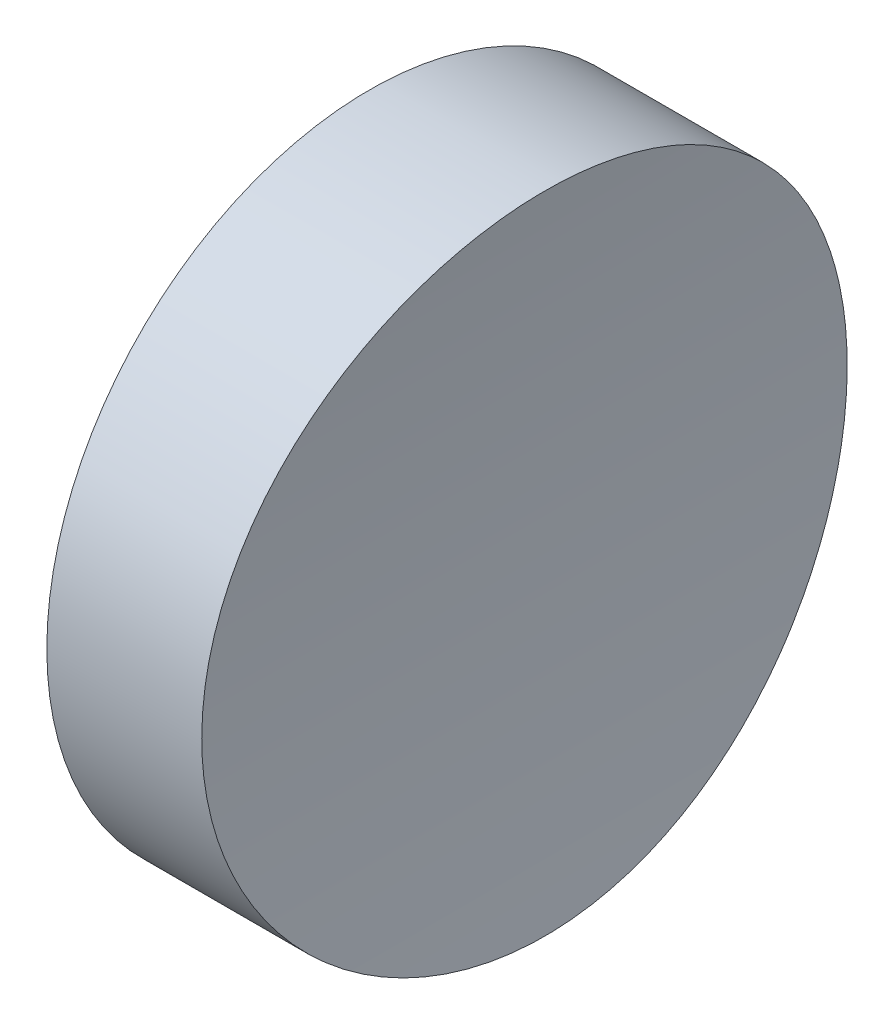
from build123d import *

# Parameters (mm, degrees)
SKETCH_1_R               = 6.25
EXTRUDE_1_DEPTH          = 10
SKETCH_2_R               = 50
CUT_EXTRUDE_1_DEPTH      = 7.25
CUT_EXTRUDE_1_DEPTH_BACK = 7.25


with BuildPart() as part:
    # 草图1 → 凸台-拉伸1 (new body)
    with BuildSketch(Plane(origin=(0, 0, 0), x_dir=(0, 0, -1), z_dir=(1, 0, 0))):
        Circle(SKETCH_1_R)
    extrude(amount=EXTRUDE_1_DEPTH)

    # 草图2 → 切除-拉伸1 (cut, two sides)
    with BuildSketch(Plane.XY) as cut_extrude_1_sk:
        with Locations((53, 0)):
            Circle(SKETCH_2_R)
    extrude(amount=CUT_EXTRUDE_1_DEPTH, mode=Mode.SUBTRACT)
    extrude(cut_extrude_1_sk.sketch, amount=-CUT_EXTRUDE_1_DEPTH_BACK, mode=Mode.SUBTRACT)


solid = part.part
